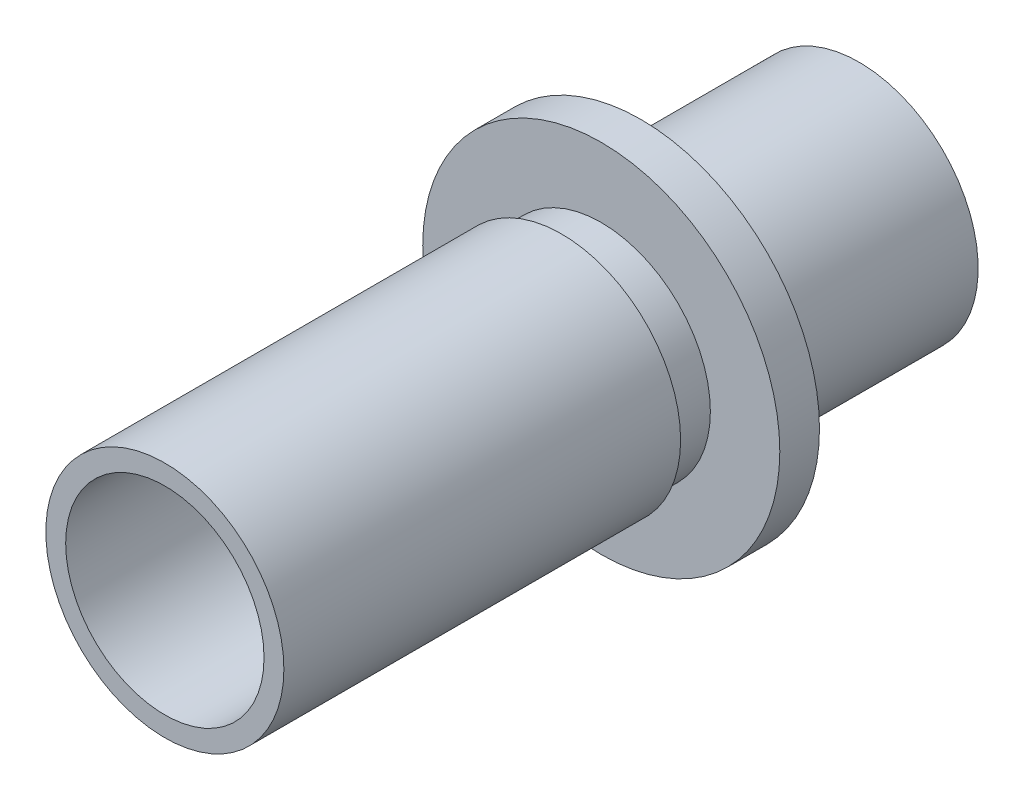
from build123d import *

# Parameters (mm, degrees)
ESQUISSE1_R        = 6
ESQUISSE1_R_2      = 5
BOSS_EXTRU_1_DEPTH = 10
ESQUISSE2_R        = 6
ESQUISSE2_R_2      = 4.5
BOSS_EXTRU_2_DEPTH = 1
ESQUISSE3_R        = 9
ESQUISSE3_R_2      = 5
BOSS_EXTRU_3_DEPTH = 2
ESQUISSE4_R        = 5.5
ESQUISSE4_R_2      = 5
BOSS_EXTRU_4_DEPTH = 2
ESQUISSE5_R        = 6
ESQUISSE5_R_2      = 5
BOSS_EXTRU_5_DEPTH = 10
ESQUISSE6_R        = 6
ESQUISSE6_R_2      = 5
BOSS_EXTRU_6_DEPTH = 10


with BuildPart() as part:
    # Esquisse1 → Boss.-Extru.1 (new body)
    with BuildSketch(Plane.XY):
        Circle(ESQUISSE1_R)
        Circle(ESQUISSE1_R_2, mode=Mode.SUBTRACT)
    extrude(amount=BOSS_EXTRU_1_DEPTH)

    # Esquisse2 → Boss.-Extru.2 (add)
    with BuildSketch(Plane(origin=(0, 0, 0), x_dir=(-1, 0, 0), z_dir=(0, 0, -1))):
        Circle(ESQUISSE2_R)
        Circle(ESQUISSE2_R_2, mode=Mode.SUBTRACT)
    extrude(amount=BOSS_EXTRU_2_DEPTH)

    # Esquisse3 → Boss.-Extru.3 (add)
    with BuildSketch(Plane.XY.offset(10)):
        Circle(ESQUISSE3_R)
        Circle(ESQUISSE3_R_2, mode=Mode.SUBTRACT)
    extrude(amount=BOSS_EXTRU_3_DEPTH)

    # Esquisse4 → Boss.-Extru.4 (add)
    with BuildSketch(Plane.XY.offset(12)):
        Circle(ESQUISSE4_R)
        Circle(ESQUISSE4_R_2, mode=Mode.SUBTRACT)
    extrude(amount=BOSS_EXTRU_4_DEPTH)

    # Esquisse5 → Boss.-Extru.5 (add)
    with BuildSketch(Plane.XY.offset(14)):
        Circle(ESQUISSE5_R)
        Circle(ESQUISSE5_R_2, mode=Mode.SUBTRACT)
    extrude(amount=BOSS_EXTRU_5_DEPTH)

    # Esquisse6 → Boss.-Extru.6 (add)
    with BuildSketch(Plane.XY.offset(24)):
        Circle(ESQUISSE6_R)
        Circle(ESQUISSE6_R_2, mode=Mode.SUBTRACT)
    extrude(amount=BOSS_EXTRU_6_DEPTH)


solid = part.part
